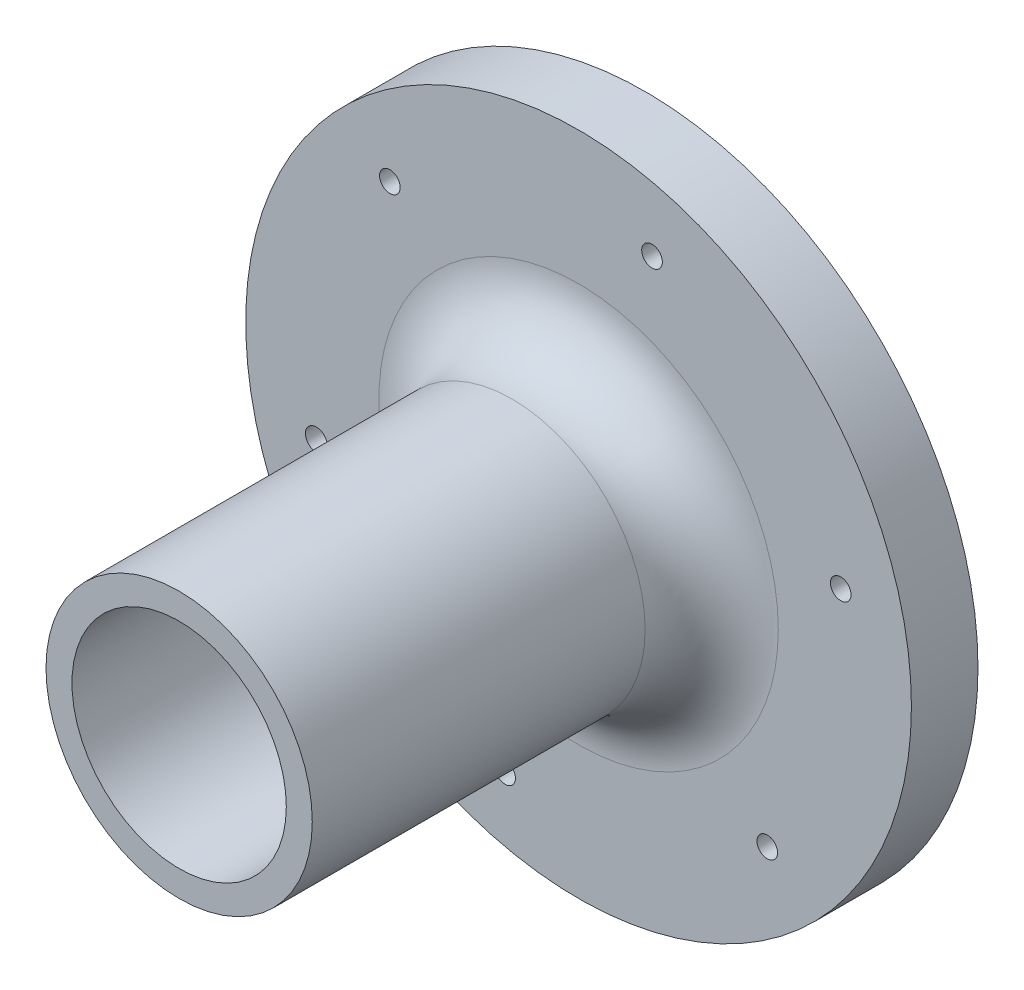
from build123d import *

# Parameters (mm, degrees)
SKETCH1_R           = 50
SKETCH1_R_2         = 16.5
SKETCH1_R_3         = 1.55
SKETCH1_R_4         = 1.649528324
BOSS_EXTRUDE1_DEPTH = 10
SKETCH2_R           = 20
SKETCH2_R_2         = 16.1
BOSS_EXTRUDE2_DEPTH = 60
FILLET1_R           = 10


with BuildPart() as part:
    # Sketch1 → Boss-Extrude1 (new body)
    with BuildSketch(Plane.XY):
        Circle(SKETCH1_R)
        Circle(SKETCH1_R_2, mode=Mode.SUBTRACT)
        with Locations((-11.034036049, -39.098354169)):
            Circle(SKETCH1_R_3, mode=Mode.SUBTRACT)
        with Locations((-39.377185981, -9.99342156)):
            Circle(SKETCH1_R_4, mode=Mode.SUBTRACT)
        with Locations((-28.343149932, 29.104932609)):
            Circle(SKETCH1_R_3, mode=Mode.SUBTRACT)
        with Locations((11.034036049, 39.098354169)):
            Circle(SKETCH1_R_3, mode=Mode.SUBTRACT)
        with Locations((39.377185981, 9.99342156)):
            Circle(SKETCH1_R_3, mode=Mode.SUBTRACT)
        with Locations((28.343149932, -29.104932609)):
            Circle(SKETCH1_R_3, mode=Mode.SUBTRACT)
    extrude(amount=BOSS_EXTRUDE1_DEPTH)

    # Sketch2 → Boss-Extrude2 (add)
    with BuildSketch(Plane.XY.offset(10)):
        Circle(SKETCH2_R)
        Circle(SKETCH2_R_2, mode=Mode.SUBTRACT)
    extrude(amount=BOSS_EXTRUDE2_DEPTH)

    # Fillet1
    fillet1_edges = [part.edges().sort_by_distance(p)[0] for p in [
        (-20, 0, 10),
    ]]
    fillet(fillet1_edges, radius=FILLET1_R)


solid = part.part
